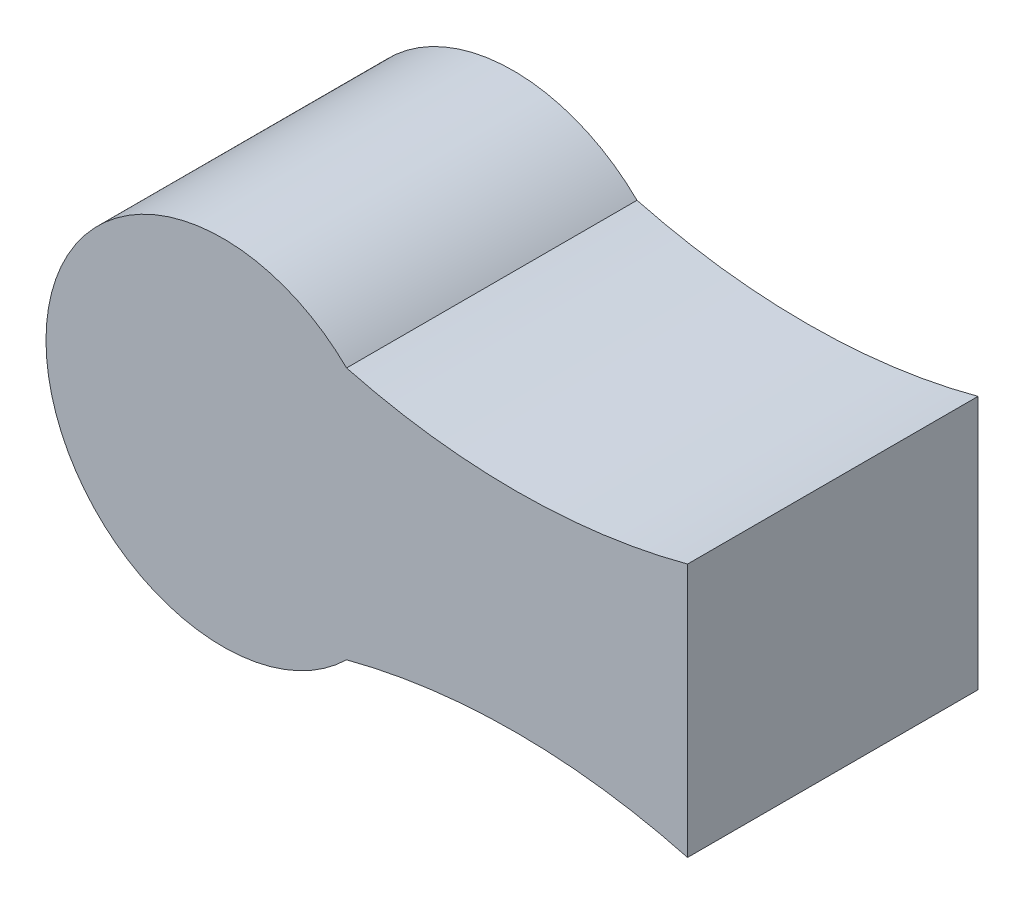
from build123d import *

# Parameters (mm, degrees)
DODANIE_WYCI_GNI_CIE2_DEPTH     = 80
SZKIC5_W                        = 35.6
SZKIC5_H                        = 35.6
WYTNIJ_WYCI_GNI_CIE1_DEPTH      = 17.8
WYTNIJ_WYCI_GNI_CIE1_DEPTH_BACK = 17.8


with BuildPart() as part:
    # Szkic2 → Dodanie-wyciągnięcie2 (new body)
    with BuildSketch(Plane.XY):
        with BuildLine():
            Line((175.492718802, -24.168338507), (175.492718802, 45.831661493))
            ThreePointArc((175.492718802, 45.831661493), (128.54386121, 39.614419972), (81.570021048, 45.640003906))
            ThreePointArc((81.570021048, 45.640003906), (-1.219530478, 10.831661493), (81.570021048, -23.976680919))
            ThreePointArc((81.570021048, -23.976680919), (128.54386121, -17.951096985), (175.492718802, -24.168338507))
        make_face()
    extrude(amount=DODANIE_WYCI_GNI_CIE2_DEPTH)

    # Szkic5 → Wytnij-wyciągnięcie1 (cut, two sides)
    with BuildSketch(Plane.XY.offset(40)) as wytnij_wyci_gni_cie1_sk:
        with Locations((135.198453221, 10.831661493)):
            Rectangle(SZKIC5_W, SZKIC5_H)
    extrude(amount=WYTNIJ_WYCI_GNI_CIE1_DEPTH, mode=Mode.SUBTRACT)
    extrude(wytnij_wyci_gni_cie1_sk.sketch, amount=-WYTNIJ_WYCI_GNI_CIE1_DEPTH_BACK, mode=Mode.SUBTRACT)


solid = part.part
